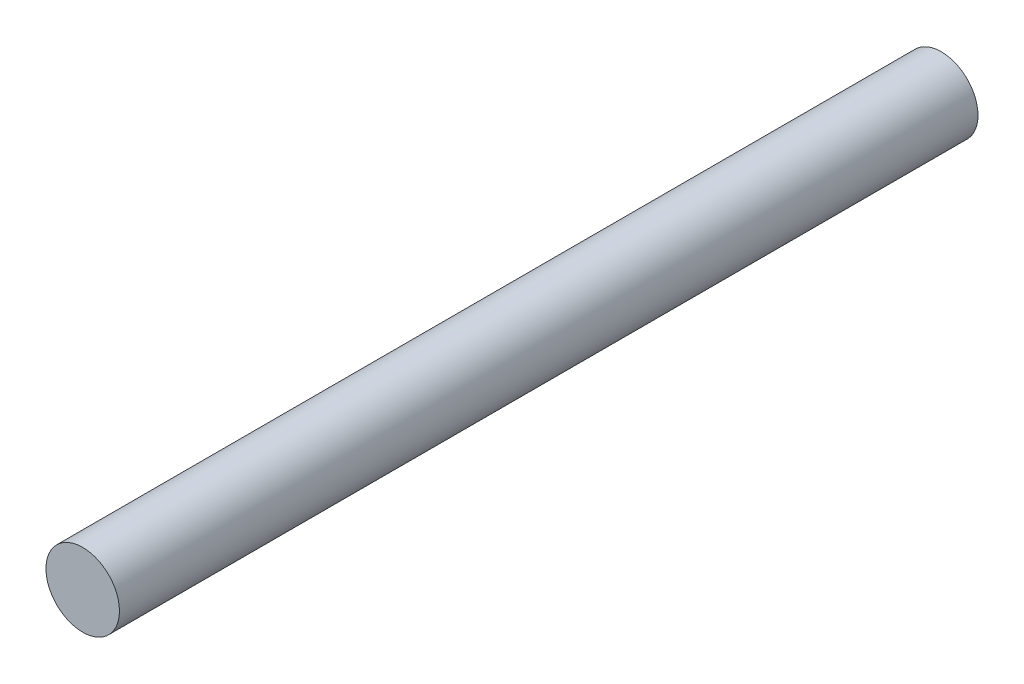
from build123d import *

# Parameters (mm, degrees)
SKETCH1_R           = 2.38125
BOSS_EXTRUDE1_DEPTH = 55.626


with BuildPart() as part:
    # Sketch1 → Boss-Extrude1 (new body)
    with BuildSketch(Plane.XY):
        Circle(SKETCH1_R)
    extrude(amount=BOSS_EXTRUDE1_DEPTH)


solid = part.part
